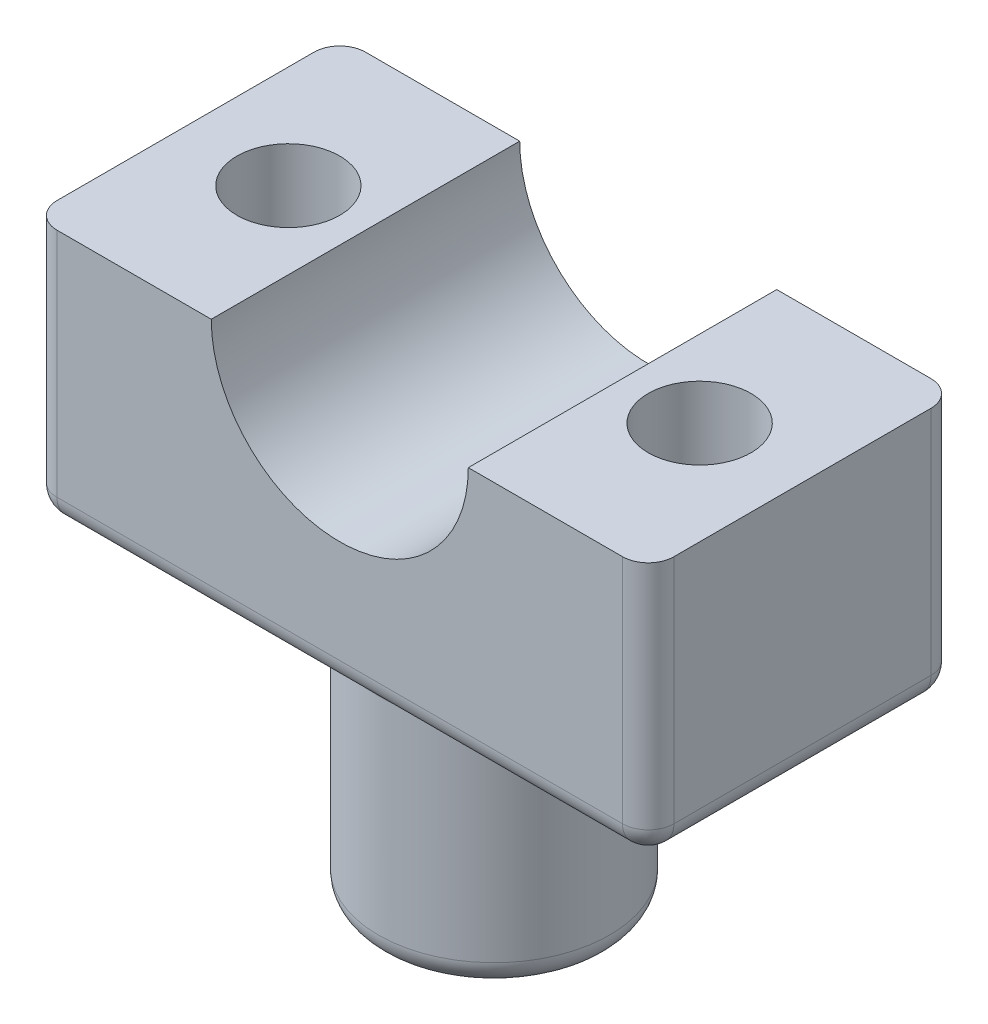
from build123d import *

# Parameters (mm, degrees)
SKETCH1_R           = 2
BOSS_EXTRUDE1_DEPTH = 10
SKETCH1_3_R         = 4.5
BOSS_EXTRUDE2_DEPTH = 10
CUT_EXTRUDE1_DEPTH  = 20.697715604
FILLET1_R           = 1
FILLET2_R           = 1
SKETCH3_R           = 2.5
CUT_EXTRUDE2_DEPTH  = 10


with BuildPart() as part:
    # Sketch1 → Boss-Extrude1 (new body)
    with BuildSketch(Plane(origin=(0, 0, 0), x_dir=(1, 0, 0), z_dir=(0, 1, 0))):
        with BuildLine():
            ThreePointArc((-12, -5), (-11.707106781, -5.707106781), (-11, -6))
            Line((-11, -6), (11, -6))
            ThreePointArc((11, -6), (11.707106781, -5.707106781), (12, -5))
            Line((12, -5), (12, 5))
            ThreePointArc((12, 5), (11.707106781, 5.707106781), (11, 6))
            Line((11, 6), (-11, 6))
            ThreePointArc((-11, 6), (-11.707106781, 5.707106781), (-12, 5))
            Line((-12, 5), (-12, -5))
        make_face()
        with Locations((-8, 0)):
            Circle(SKETCH1_R, mode=Mode.SUBTRACT)
        with Locations((8, 0)):
            Circle(SKETCH1_R, mode=Mode.SUBTRACT)
    extrude(amount=BOSS_EXTRUDE1_DEPTH)

    # Sketch1_3 → Boss-Extrude2 (add)
    with BuildSketch(Plane(origin=(0, 0, 0), x_dir=(1, 0, 0), z_dir=(0, 1, 0))):
        Circle(SKETCH1_3_R)
    extrude(amount=-BOSS_EXTRUDE2_DEPTH)

    # Sketch2 → Cut-Extrude1 (cut, through all)
    with BuildSketch(Plane.XY.offset(6)):
        with BuildLine():
            Line((-5, 10), (5, 10))
            ThreePointArc((5, 10), (0, 5), (-5, 10))
        make_face()
    extrude(amount=-CUT_EXTRUDE1_DEPTH, mode=Mode.SUBTRACT)

    # Fillet1
    fillet1_edges = [part.edges().sort_by_distance(p)[0] for p in [
        (-11.707106781, 0, 5.707106781),
        (-12, 0, 0),
        (-11.707106781, 0, -5.707106781),
        (0, 0, -6),
        (11.707106781, 0, -5.707106781),
        (12, 0, 0),
        (11.707106781, 0, 5.707106781),
        (-4.5, -10, 0),
        (0, 0, 6),
    ]]
    fillet(fillet1_edges, radius=FILLET1_R)

    # Fillet2
    fillet2_edges = [part.edges().sort_by_distance(p)[0] for p in [
        (-4.5, 0, 0),
    ]]
    fillet(fillet2_edges, radius=FILLET2_R)

    # Sketch3 → Cut-Extrude2 (cut)
    with BuildSketch(Plane.XZ.offset(10)):
        Circle(SKETCH3_R)
    extrude(amount=-CUT_EXTRUDE2_DEPTH, mode=Mode.SUBTRACT)


solid = part.part
